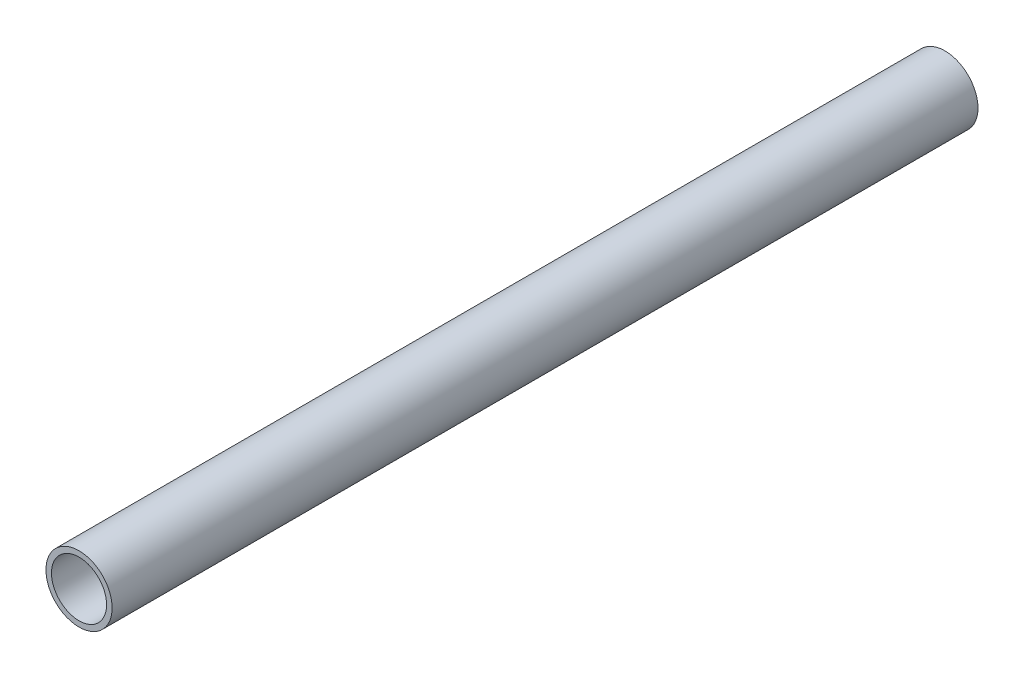
from build123d import *

# Parameters (mm, degrees)
SKETCH1_R           = 6
SKETCH1_R_2         = 5
BOSS_EXTRUDE1_DEPTH = 157


with BuildPart() as part:
    # Sketch1 → Boss-Extrude1 (new body)
    with BuildSketch(Plane.XY):
        Circle(SKETCH1_R)
        Circle(SKETCH1_R_2, mode=Mode.SUBTRACT)
    extrude(amount=BOSS_EXTRUDE1_DEPTH)


solid = part.part
